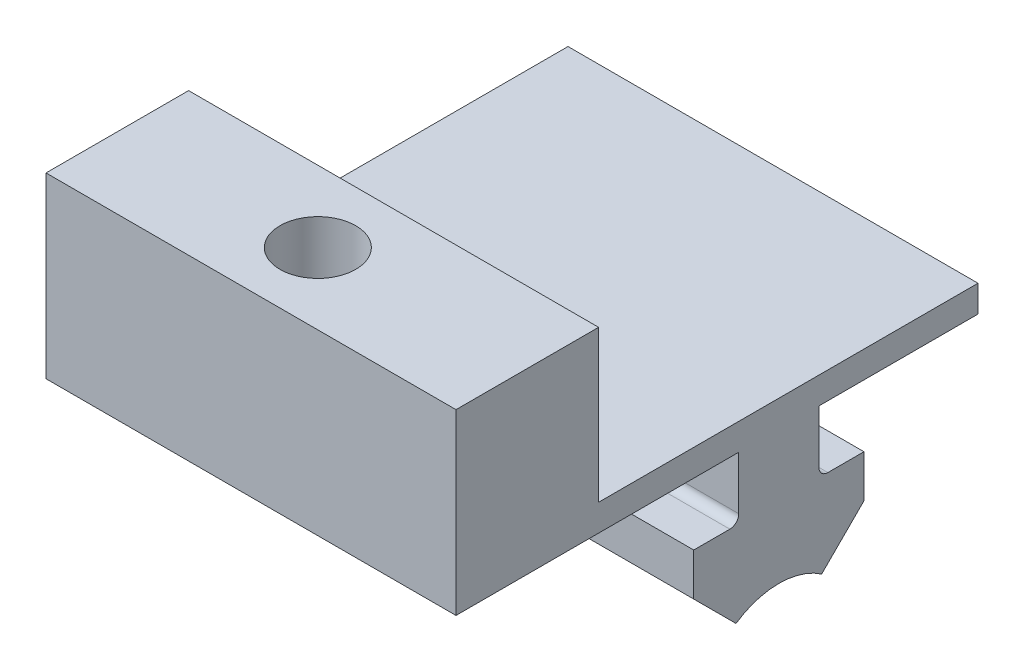
from build123d import *

# Parameters (mm, degrees)
BOSS_EXTRUDE1_DEPTH = 46
SKETCH2_R           = 4.25
CUT_EXTRUDE1_DEPTH  = 10


with BuildPart() as part:
    # Sketch1 → Boss-Extrude1 (new body)
    with BuildSketch(Plane(origin=(632.1, 0, 0), x_dir=(0, 0, -1), z_dir=(1, 0, 0))):
        with BuildLine():
            Line((277.8, -589.1), (277.8, -586.1))
            Line((277.8, -586.1), (246.077000521, -586.1))
            Line((246.077000521, -586.1), (246.077000521, -566.1))
            Line((246.077000521, -566.1), (262.077000521, -566.1))
            Line((262.077000521, -566.1), (262.077000521, -583.1))
            Line((262.077000521, -583.1), (304.643123208, -583.1))
            Line((304.643123208, -583.1), (304.643123208, -586.1))
            Line((304.643123208, -586.1), (286.8, -586.1))
            Line((286.8, -586.1), (286.8, -589.1))
            Line((286.8, -589.1), (286.8, -592.075))
            ThreePointArc((286.8, -592.075), (287.092893219, -592.782106781), (287.8, -593.075))
            Line((287.8, -593.075), (291.85, -593.075))
            Line((291.85, -593.075), (291.85, -597.842893219))
            Line((291.85, -597.842893219), (287.104675609, -602.58821761))
            ThreePointArc((287.104675609, -602.58821761), (282.3, -601.1), (277.495324391, -602.58821761))
            Line((277.495324391, -602.58821761), (272.75, -597.842893219))
            Line((272.75, -597.842893219), (272.75, -593.075))
            Line((272.75, -593.075), (276.8, -593.075))
            ThreePointArc((276.8, -593.075), (277.507106781, -592.782106781), (277.8, -592.075))
            Line((277.8, -592.075), (277.8, -589.1))
        make_face()
    extrude(amount=-BOSS_EXTRUDE1_DEPTH)

    # Sketch2 → Cut-Extrude1 (cut)
    with BuildSketch(Plane(origin=(0, -566.1, 0), x_dir=(1, 0, 0), z_dir=(0, 1, 0))):
        with Locations((608.598456538, 254.077000521)):
            Circle(SKETCH2_R)
    extrude(amount=-CUT_EXTRUDE1_DEPTH, mode=Mode.SUBTRACT)


solid = part.part
